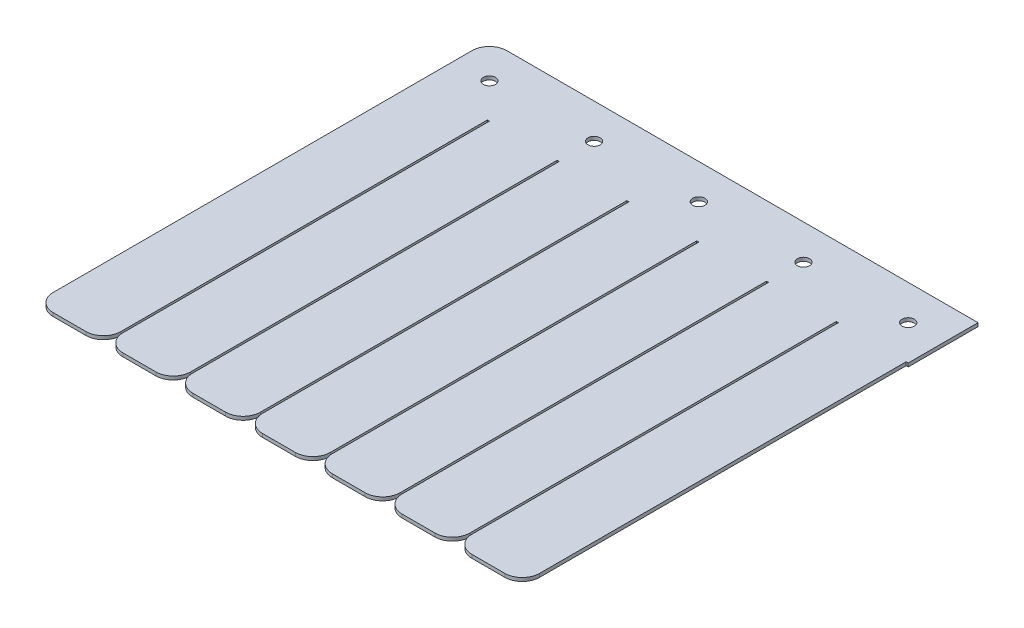
from build123d import *

# Parameters (mm, degrees)
BOSS_EXTRUDE1_DEPTH = 1
CUT_EXTRUDE1_REACH  = 3
SKETCH2_R           = 1.75


with BuildPart() as part:
    # Sketch1 → Boss-Extrude1 (new body)
    with BuildSketch(Plane(origin=(0, 0, 0), x_dir=(1, 0, 0), z_dir=(0, 1, 0))):
        with BuildLine():
            Line((39.4, -105), (39.4, 0))
            Line((39.4, 0), (40, 0))
            Line((40, 0), (40, -105))
            ThreePointArc((40, -105), (41.464466094, -108.535533906), (45, -110))
            Line((45, -110), (54.4, -110))
            ThreePointArc((54.4, -110), (57.935533906, -108.535533906), (59.4, -105))
            Line((59.4, -105), (59.4, 0))
            Line((59.4, 0), (60, 0))
            Line((60, 0), (60, -105))
            ThreePointArc((60, -105), (61.464466094, -108.535533906), (65, -110))
            Line((65, -110), (74.4, -110))
            ThreePointArc((74.4, -110), (77.935533906, -108.535533906), (79.4, -105))
            Line((79.4, -105), (79.4, 0))
            Line((79.4, 0), (80, 0))
            Line((80, 0), (80, -105))
            ThreePointArc((80, -105), (81.464466094, -108.535533906), (85, -110))
            Line((85, -110), (94.4, -110))
            ThreePointArc((94.4, -110), (97.935533906, -108.535533906), (99.4, -105))
            Line((99.4, -105), (99.4, 0))
            Line((99.4, 0), (100, 0))
            Line((100, 0), (100, -105))
            ThreePointArc((100, -105), (101.464466094, -108.535533906), (105, -110))
            Line((105, -110), (114.4, -110))
            ThreePointArc((114.4, -110), (117.935533906, -108.535533906), (119.4, -105))
            Line((119.4, -105), (119.4, 0))
            Line((119.4, 0), (120, 0))
            Line((120, 0), (120, -105))
            ThreePointArc((120, -105), (121.464466094, -108.535533906), (125, -110))
            Line((125, -110), (134.4, -110))
            ThreePointArc((134.4, -110), (137.935533906, -108.535533906), (139.4, -105))
            Line((139.4, -105), (139.4, 0))
            Line((139.4, 0), (140, 0))
            Line((140, 0), (140, 20))
            Line((140, 20), (5, 20))
            ThreePointArc((5, 20), (1.464466094, 18.535533906), (0, 15))
            Line((0, 15), (0, -105))
            ThreePointArc((0, -105), (1.464466094, -108.535533906), (5, -110))
            Line((5, -110), (14.4, -110))
            ThreePointArc((14.4, -110), (17.935533906, -108.535533906), (19.4, -105))
            Line((19.4, -105), (19.4, 0))
            Line((19.4, 0), (20, 0))
            Line((20, 0), (20, -105))
            ThreePointArc((20, -105), (21.464466094, -108.535533906), (25, -110))
            Line((25, -110), (34.4, -110))
            ThreePointArc((34.4, -110), (37.935533906, -108.535533906), (39.4, -105))
        make_face()
    extrude(amount=BOSS_EXTRUDE1_DEPTH)

    # Sketch2 → Cut-Extrude1 (cut, up to next)
    with BuildSketch(Plane(origin=(0, 1, 0), x_dir=(1, 0, 0), z_dir=(0, 1, 0)), mode=Mode.PRIVATE) as cut_extrude1_sk1:
        with Locations((10, 10)):
            Circle(SKETCH2_R)
    cut_extrude1_tool1 = extrude(cut_extrude1_sk1.sketch, amount=-CUT_EXTRUDE1_REACH, mode=Mode.PRIVATE) & part.part
    add(cut_extrude1_tool1.solids().sort_by_distance((10, 1, -10))[0], mode=Mode.SUBTRACT)
    # Sketch2 → Cut-Extrude1 (cut, up to next)
    with BuildSketch(Plane(origin=(0, 1, 0), x_dir=(1, 0, 0), z_dir=(0, 1, 0)), mode=Mode.PRIVATE) as cut_extrude1_sk2:
        with Locations((40, 10)):
            Circle(SKETCH2_R)
    cut_extrude1_tool2 = extrude(cut_extrude1_sk2.sketch, amount=-CUT_EXTRUDE1_REACH, mode=Mode.PRIVATE) & part.part
    add(cut_extrude1_tool2.solids().sort_by_distance((40, 1, -10))[0], mode=Mode.SUBTRACT)
    # Sketch2 → Cut-Extrude1 (cut, up to next)
    with BuildSketch(Plane(origin=(0, 1, 0), x_dir=(1, 0, 0), z_dir=(0, 1, 0)), mode=Mode.PRIVATE) as cut_extrude1_sk3:
        with Locations((70, 10)):
            Circle(SKETCH2_R)
    cut_extrude1_tool3 = extrude(cut_extrude1_sk3.sketch, amount=-CUT_EXTRUDE1_REACH, mode=Mode.PRIVATE) & part.part
    add(cut_extrude1_tool3.solids().sort_by_distance((70, 1, -10))[0], mode=Mode.SUBTRACT)
    # Sketch2 → Cut-Extrude1 (cut, up to next)
    with BuildSketch(Plane(origin=(0, 1, 0), x_dir=(1, 0, 0), z_dir=(0, 1, 0)), mode=Mode.PRIVATE) as cut_extrude1_sk4:
        with Locations((100, 10)):
            Circle(SKETCH2_R)
    cut_extrude1_tool4 = extrude(cut_extrude1_sk4.sketch, amount=-CUT_EXTRUDE1_REACH, mode=Mode.PRIVATE) & part.part
    add(cut_extrude1_tool4.solids().sort_by_distance((100, 1, -10))[0], mode=Mode.SUBTRACT)
    # Sketch2 → Cut-Extrude1 (cut, up to next)
    with BuildSketch(Plane(origin=(0, 1, 0), x_dir=(1, 0, 0), z_dir=(0, 1, 0)), mode=Mode.PRIVATE) as cut_extrude1_sk5:
        with Locations((130, 10)):
            Circle(SKETCH2_R)
    cut_extrude1_tool5 = extrude(cut_extrude1_sk5.sketch, amount=-CUT_EXTRUDE1_REACH, mode=Mode.PRIVATE) & part.part
    add(cut_extrude1_tool5.solids().sort_by_distance((130, 1, -10))[0], mode=Mode.SUBTRACT)


solid = part.part
